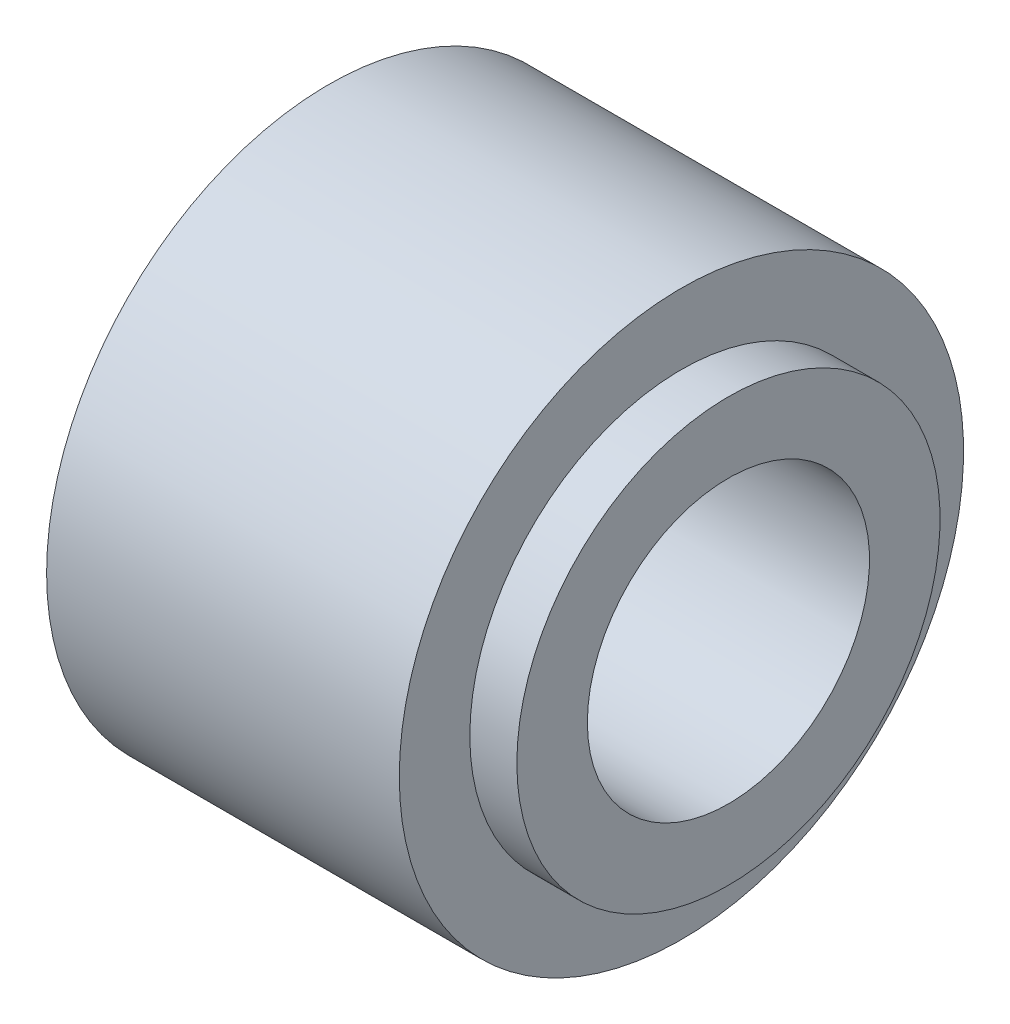
from build123d import *


with BuildPart() as part:
    # Sketch1 → Revolve1 (revolve)
    with BuildSketch(Plane.XY):
        Polygon((0, 6), (0, 3), (8.5, 3), (8.5, 4.5), (7.5, 4.5), (7.5, 6), align=None)
    revolve(axis=Axis((0, 0, 0), (1, 0, 0)))


solid = part.part
